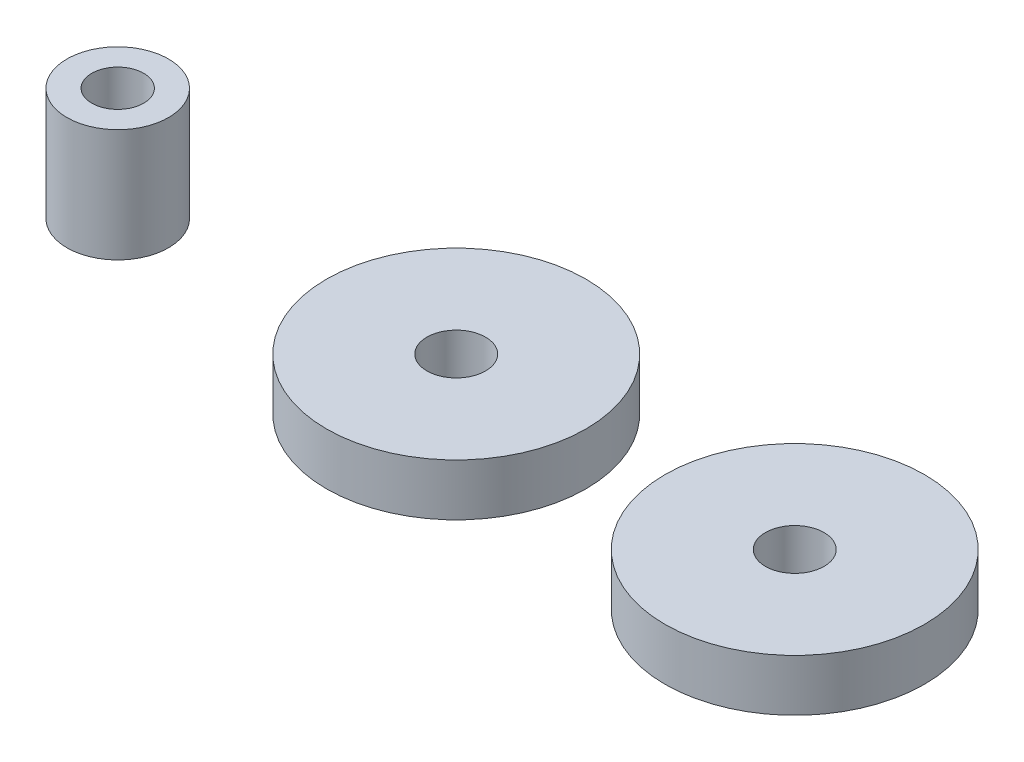
from build123d import *

# Parameters (mm, degrees)
SKETCH1_R             = 2.25
SKETCH1_R_2           = 1.15
BOSS_EXTRUDE1_DEPTH   = 5
SKETCH2_R             = 5.75
SKETCH2_R_2           = 1.3
BOSS_EXTRUDE2_DEPTH   = 2.3
BOSS_EXTRUDE2_2_DEPTH = 2.3


with BuildPart() as part:
    # Sketch1 → Boss-Extrude1 (new body)
    with BuildSketch(Plane(origin=(0, 0, 0), x_dir=(1, 0, 0), z_dir=(0, 1, 0))):
        Circle(SKETCH1_R)
        Circle(SKETCH1_R_2, mode=Mode.SUBTRACT)
    extrude(amount=BOSS_EXTRUDE1_DEPTH)


with BuildPart() as body_2:
    # Sketch2 → Boss-Extrude2 (new body)
    with BuildSketch(Plane(origin=(0, 0, 0), x_dir=(1, 0, 0), z_dir=(0, 1, 0))):
        with Locations((15, 0)):
            Circle(SKETCH2_R)
        with Locations((15, 0)):
            Circle(SKETCH2_R_2, mode=Mode.SUBTRACT)
    extrude(amount=BOSS_EXTRUDE2_DEPTH)


with BuildPart() as body_3:
    # Sketch2 → Boss-Extrude2 2 (new body)
    with BuildSketch(Plane(origin=(0, 0, 0), x_dir=(1, 0, 0), z_dir=(0, 1, 0))):
        with Locations((30, 0)):
            Circle(SKETCH2_R)
        with Locations((30, 0)):
            Circle(SKETCH2_R_2, mode=Mode.SUBTRACT)
    extrude(amount=BOSS_EXTRUDE2_2_DEPTH)


solid = Compound([part.part, body_2.part, body_3.part])
